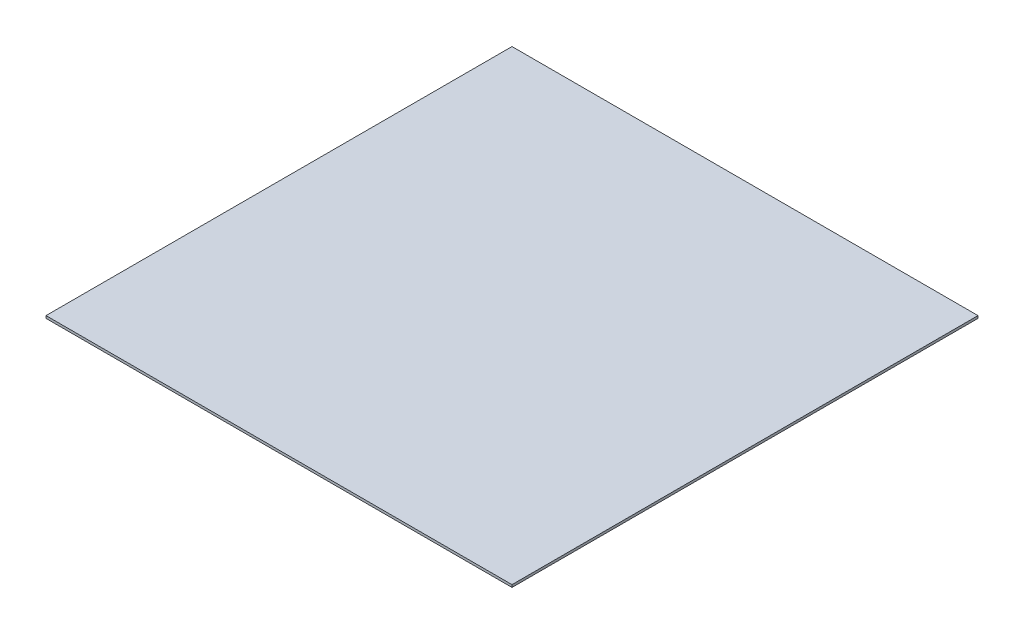
from build123d import *

# Parameters (mm, degrees)
SKETCH1_W           = 19000
SKETCH1_H           = 19000
BOSS_EXTRUDE1_DEPTH = 100


with BuildPart() as part:
    # Sketch1 → Boss-Extrude1 (new body)
    with BuildSketch(Plane(origin=(0, 0, 0), x_dir=(1, 0, 0), z_dir=(0, 1, 0))):
        with Locations((9500, -9500)):
            Rectangle(SKETCH1_W, SKETCH1_H)
    extrude(amount=BOSS_EXTRUDE1_DEPTH)


solid = part.part
